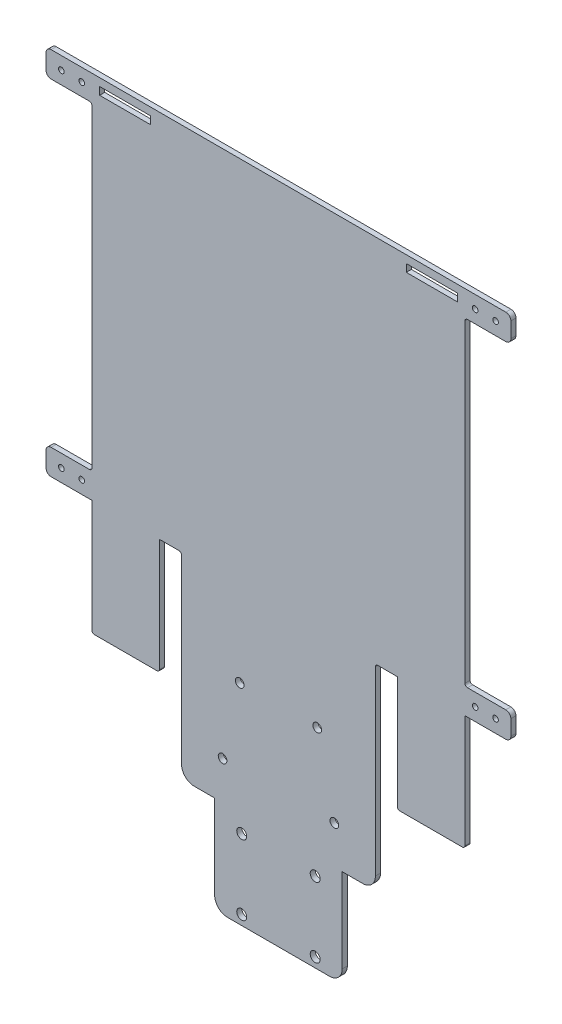
from build123d import *

# Parameters (mm, degrees)
SKETCH1_R           = 1.95
SKETCH1_R_2         = 1.1
SKETCH1_R_3         = 1.7
SKETCH1_W           = 20
SKETCH1_H           = 3
BOSS_EXTRUDE2_DEPTH = 2


with BuildPart() as part:
    # Sketch1 → Boss-Extrude2 (new body)
    with BuildSketch(Plane.XY):
        with BuildLine():
            Line((-132.281780802, 145), (45.918219198, 145))
            ThreePointArc((45.918219198, 145), (47.332432761, 144.414213562), (47.918219198, 143))
            Line((47.918219198, 143), (47.918219198, 137))
            ThreePointArc((47.918219198, 137), (47.332432761, 135.585786438), (45.918219198, 135))
            Line((45.918219198, 135), (30.918219198, 135))
            ThreePointArc((30.918219198, 135), (30.211112417, 134.707106781), (29.918219198, 134))
            Line((29.918219198, 134), (29.918219198, 11))
            ThreePointArc((29.918219198, 11), (30.211112417, 10.292893219), (30.918219198, 10))
            Line((30.918219198, 10), (45.918219198, 10))
            ThreePointArc((45.918219198, 10), (47.332432761, 9.414213562), (47.918219198, 8))
            Line((47.918219198, 8), (47.918219198, 2))
            ThreePointArc((47.918219198, 2), (47.332432761, 0.585786438), (45.918219198, 0))
            Line((45.918219198, 0), (29.918219198, 0))
            Line((29.918219198, 0), (29.918219198, -44.1))
            ThreePointArc((29.918219198, -44.1), (29.62532598, -44.807106781), (28.918219198, -45.1))
            Line((28.918219198, -45.1), (4.418219198, -45.1))
            ThreePointArc((4.418219198, -45.1), (3.711112417, -44.807106781), (3.418219198, -44.1))
            Line((3.418219198, -44.1), (3.418219198, 0))
            Line((3.418219198, 0), (-4.181780802, 0))
            ThreePointArc((-4.181780802, 0), (-4.888887583, -0.292893219), (-5.181780802, -1))
            Line((-5.181780802, -1), (-5.181780802, -72))
            ThreePointArc((-5.181780802, -72), (-6.646246896, -75.535533906), (-10.181780802, -77))
            Line((-10.181780802, -77), (-18.181780802, -77))
            Line((-18.181780802, -77), (-18.181780802, -110))
            ThreePointArc((-18.181780802, -110), (-19.646246896, -113.535533906), (-23.181780802, -115))
            Line((-23.181780802, -115), (-63.181780802, -115))
            ThreePointArc((-63.181780802, -115), (-66.717314707, -113.535533906), (-68.181780802, -110))
            Line((-68.181780802, -110), (-68.181780802, -77))
            Line((-68.181780802, -77), (-76.181780802, -77))
            ThreePointArc((-76.181780802, -77), (-79.717314707, -75.535533906), (-81.181780802, -72))
            Line((-81.181780802, -72), (-81.181780802, -1))
            ThreePointArc((-81.181780802, -1), (-81.47467402, -0.292893219), (-82.181780802, 0))
            Line((-82.181780802, 0), (-89.781780802, 0))
            Line((-89.781780802, 0), (-89.781780802, -44.1))
            ThreePointArc((-89.781780802, -44.1), (-90.07467402, -44.807106781), (-90.781780802, -45.1))
            Line((-90.781780802, -45.1), (-115.281780802, -45.1))
            ThreePointArc((-115.281780802, -45.1), (-115.988887583, -44.807106781), (-116.281780802, -44.1))
            Line((-116.281780802, -44.1), (-116.281780802, 0))
            Line((-116.281780802, 0), (-132.281780802, 0))
            ThreePointArc((-132.281780802, 0), (-133.695994364, 0.585786438), (-134.281780802, 2))
            Line((-134.281780802, 2), (-134.281780802, 8))
            ThreePointArc((-134.281780802, 8), (-133.695994364, 9.414213562), (-132.281780802, 10))
            Line((-132.281780802, 10), (-117.281780802, 10))
            ThreePointArc((-117.281780802, 10), (-116.57467402, 10.292893219), (-116.281780802, 11))
            Line((-116.281780802, 11), (-116.281780802, 134))
            ThreePointArc((-116.281780802, 134), (-116.57467402, 134.707106781), (-117.281780802, 135))
            Line((-117.281780802, 135), (-132.281780802, 135))
            ThreePointArc((-132.281780802, 135), (-133.695994364, 135.585786438), (-134.281780802, 137))
            Line((-134.281780802, 137), (-134.281780802, 143))
            ThreePointArc((-134.281780802, 143), (-133.695994364, 144.414213562), (-132.281780802, 145))
        make_face()
        with Locations((-28.781780802, -111.2)):
            Circle(SKETCH1_R, mode=Mode.SUBTRACT)
        with Locations((41.918219198, 140)):
            Circle(SKETCH1_R_2, mode=Mode.SUBTRACT)
        with Locations((33.918219198, 140)):
            Circle(SKETCH1_R_2, mode=Mode.SUBTRACT)
        with Locations((41.918219198, 5)):
            Circle(SKETCH1_R_2, mode=Mode.SUBTRACT)
        with Locations((33.918219198, 5)):
            Circle(SKETCH1_R_2, mode=Mode.SUBTRACT)
        with Locations((-28.781780802, -83.8)):
            Circle(SKETCH1_R, mode=Mode.SUBTRACT)
        with Locations((-21.281780802, -62)):
            Circle(SKETCH1_R_3, mode=Mode.SUBTRACT)
        with Locations((-27.981780802, -33)):
            Circle(SKETCH1_R_3, mode=Mode.SUBTRACT)
        with Locations((-58.381780802, -33)):
            Circle(SKETCH1_R_3, mode=Mode.SUBTRACT)
        with Locations((-65.081780802, -62)):
            Circle(SKETCH1_R_3, mode=Mode.SUBTRACT)
        with Locations((-57.581780802, -83.8)):
            Circle(SKETCH1_R, mode=Mode.SUBTRACT)
        with Locations((-120.281780802, 5)):
            Circle(SKETCH1_R_2, mode=Mode.SUBTRACT)
        with Locations((-128.281780802, 5)):
            Circle(SKETCH1_R_2, mode=Mode.SUBTRACT)
        with Locations((-120.281780802, 140)):
            Circle(SKETCH1_R_2, mode=Mode.SUBTRACT)
        with Locations((-128.281780802, 140)):
            Circle(SKETCH1_R_2, mode=Mode.SUBTRACT)
        with Locations((-57.581780802, -111.2)):
            Circle(SKETCH1_R, mode=Mode.SUBTRACT)
        with Locations((-103.281780802, 140.5)):
            Rectangle(SKETCH1_W, SKETCH1_H, mode=Mode.SUBTRACT)
        with Locations((16.918219198, 140.5)):
            Rectangle(SKETCH1_W, SKETCH1_H, mode=Mode.SUBTRACT)
    extrude(amount=BOSS_EXTRUDE2_DEPTH)


solid = part.part
